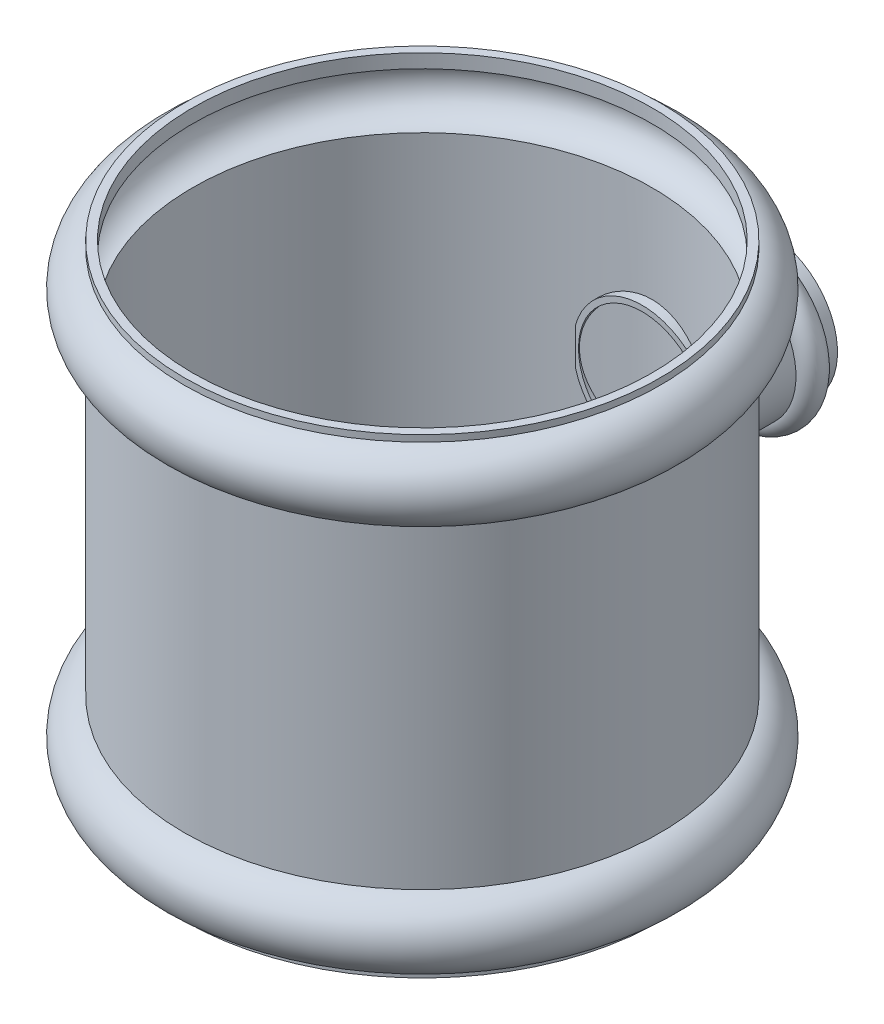
from build123d import *


with BuildPart() as part:
    # Эскиз2 → Повернуть-Тонкостенный1 (revolve)
    with BuildSketch(Plane.XY):
        with BuildLine():
            Line((83, 84.999999301), (83, 79.999999301))
            ThreePointArc((83, 79.999999301), (92.999999301, 70), (83, 60.000000699))
            Line((83, 60.000000699), (83, -60))
            ThreePointArc((83, -60), (93, -70), (83, -80))
            Line((83, -80), (83, -85))
            Line((83, -85), (86, -85))
            Line((86, -85), (86, -82.649110641))
            ThreePointArc((86, -82.649110641), (96, -70), (86, -57.350889359))
            Line((86, -57.350889359), (86, 57.350890078))
            ThreePointArc((86, 57.350890078), (95.999999301, 70), (86, 82.649109922))
            Line((86, 82.649109922), (86, 84.999999301))
            Line((86, 84.999999301), (83, 84.999999301))
        make_face()
    revolve(axis=Axis((0, 137.813713198, 0), (0, -1, 0)))

    # Эскиз3 → Повернуть-Тонкостенный3 (revolve)
    with BuildSketch(Plane(origin=(0, 0, 0), x_dir=(1, 0, 0), z_dir=(0, 1, 0))):
        with BuildLine():
            Line((25, 125), (25, 120))
            ThreePointArc((25, 120), (30, 115), (25, 110))
            Line((25, 110), (25, 79.413960704))
            Line((25, 79.413960704), (23, 79.413960704))
            Line((23, 79.413960704), (23, 112.763932023))
            ThreePointArc((23, 112.763932023), (28, 115), (23, 117.236067977))
            Line((23, 117.236067977), (23, 125))
            Line((23, 125), (25, 125))
        make_face()
    revolve(axis=Axis((0, 0, -125.398506503), (0, 0, 1)))


solid = part.part
